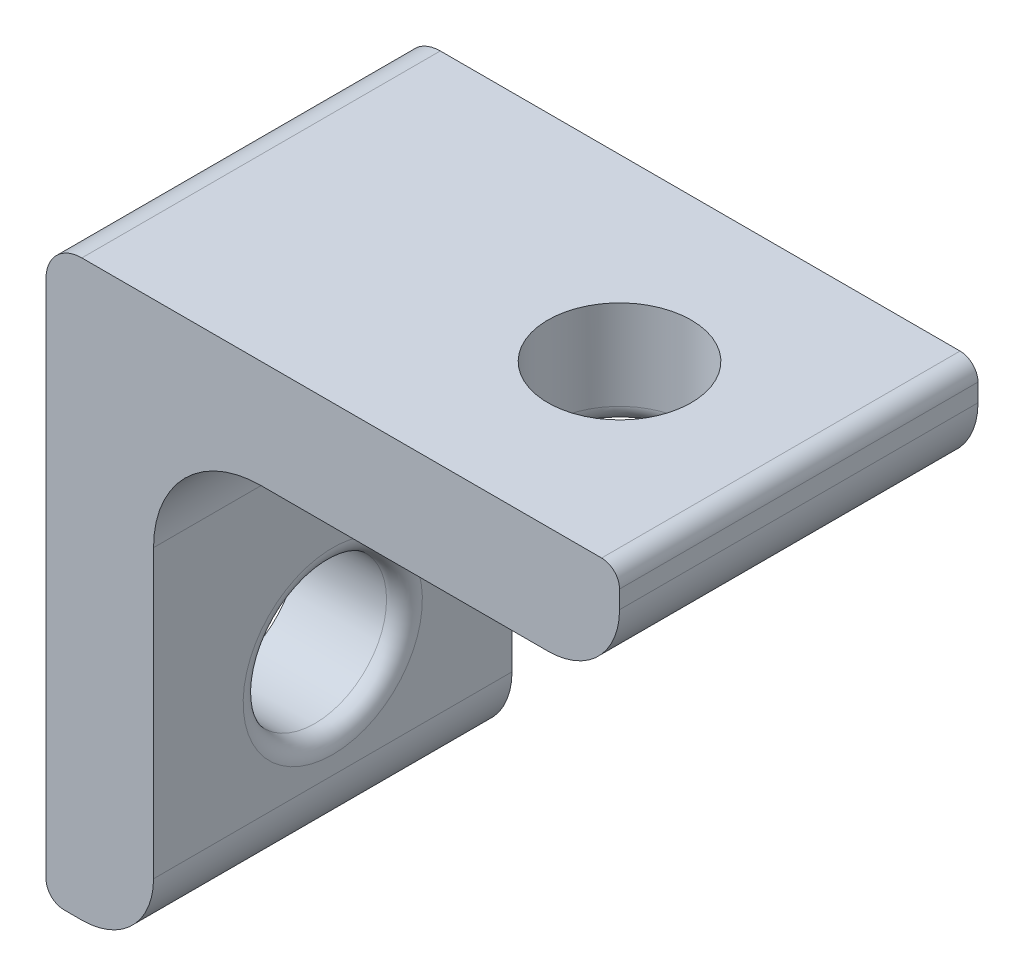
from build123d import *

# Parameters (mm, degrees)
EXTRUDE_1_DEPTH     = 10
SKETCH_4_R          = 2
CUT_EXTRUDE_1_DEPTH = 10
SKETCH_2_R          = 2
CUT_EXTRUDE_2_DEPTH = 20
FILLET_2_R          = 0.5
FILLET_3_R          = 3
FILLET_4_R          = 1


with BuildPart() as part:
    # 草图1 → 凸台-拉伸1 (new body)
    with BuildSketch(Plane.XY):
        with BuildLine():
            Line((-13, 0), (-13, -11))
            ThreePointArc((-13, -11), (-13.585786438, -12.414213562), (-15, -13))
            Line((-15, -13), (-15.5, -13))
            ThreePointArc((-15.5, -13), (-15.853553391, -12.853553391), (-16, -12.5))
            Line((-16, -12.5), (-16, 3))
            Line((-16, 3), (-0.5, 3))
            ThreePointArc((-0.5, 3), (-0.146446609, 2.853553391), (0, 2.5))
            Line((0, 2.5), (0, 2))
            ThreePointArc((0, 2), (-0.585786438, 0.585786438), (-2, 0))
            Line((-2, 0), (-13, 0))
        make_face()
    extrude(amount=EXTRUDE_1_DEPTH)

    # 草图4 → 切除-拉伸1 (cut)
    with BuildSketch(Plane(origin=(0, 0, 0), x_dir=(1, 0, 0), z_dir=(0, 1, 0))):
        with Locations((-5, -5)):
            Circle(SKETCH_4_R)
    extrude(amount=CUT_EXTRUDE_1_DEPTH, mode=Mode.SUBTRACT)

    # 草图2 → 切除-拉伸2 (cut)
    with BuildSketch(Plane(origin=(-13, 0, 0), x_dir=(0, 0, -1), z_dir=(1, 0, 0))):
        with Locations((-5, -8)):
            Circle(SKETCH_2_R)
    extrude(amount=-CUT_EXTRUDE_2_DEPTH, mode=Mode.SUBTRACT)

    # 圆角2
    fillet_2_edges = [part.edges().sort_by_distance(p)[0] for p in [
        (-7, 0, 5),
        (-13, -8, 7),
    ]]
    fillet(fillet_2_edges, radius=FILLET_2_R)

    # 圆角3
    fillet_3_edges = [part.edges().sort_by_distance(p)[0] for p in [
        (-13, 0, 5),
    ]]
    fillet(fillet_3_edges, radius=FILLET_3_R)

    # 圆角4
    fillet_4_edges = [part.edges().sort_by_distance(p)[0] for p in [
        (-16, 3, 5),
    ]]
    fillet(fillet_4_edges, radius=FILLET_4_R)


solid = part.part
